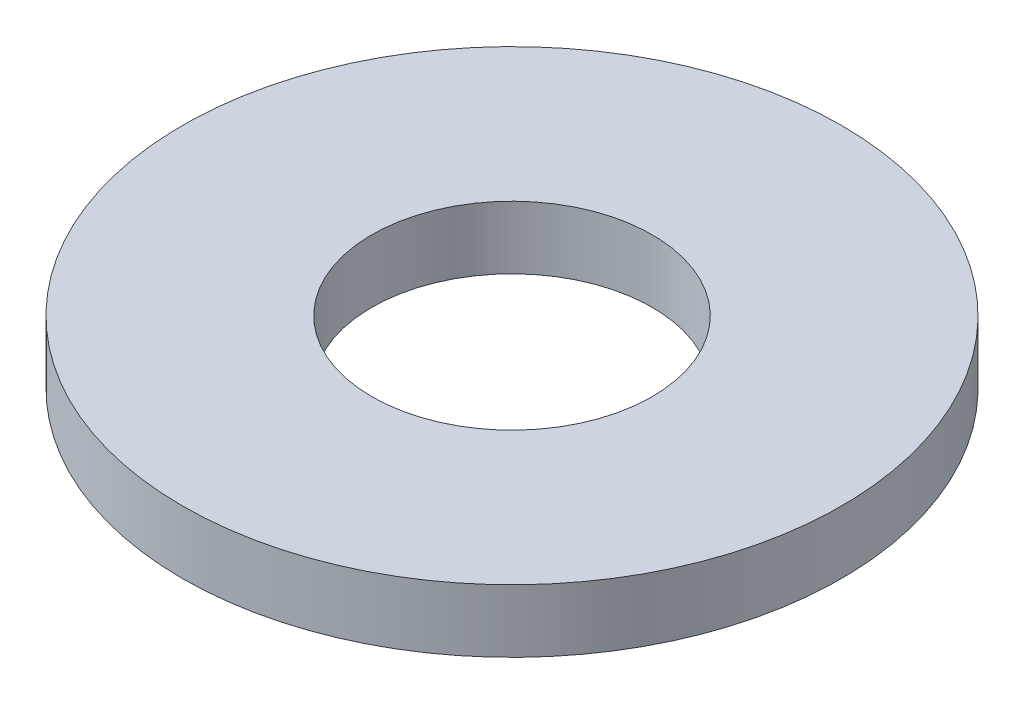
from build123d import *

# Parameters (mm, degrees)
SKETCH1_R           = 9.3265625
SKETCH1_R_2         = 3.96875
BOSS_EXTRUDE1_DEPTH = 1.78


with BuildPart() as part:
    # Sketch1 → Boss-Extrude1 (new body)
    with BuildSketch(Plane(origin=(0, 0, 0), x_dir=(1, 0, 0), z_dir=(0, 1, 0))):
        Circle(SKETCH1_R)
        Circle(SKETCH1_R_2, mode=Mode.SUBTRACT)
    extrude(amount=BOSS_EXTRUDE1_DEPTH)


solid = part.part
